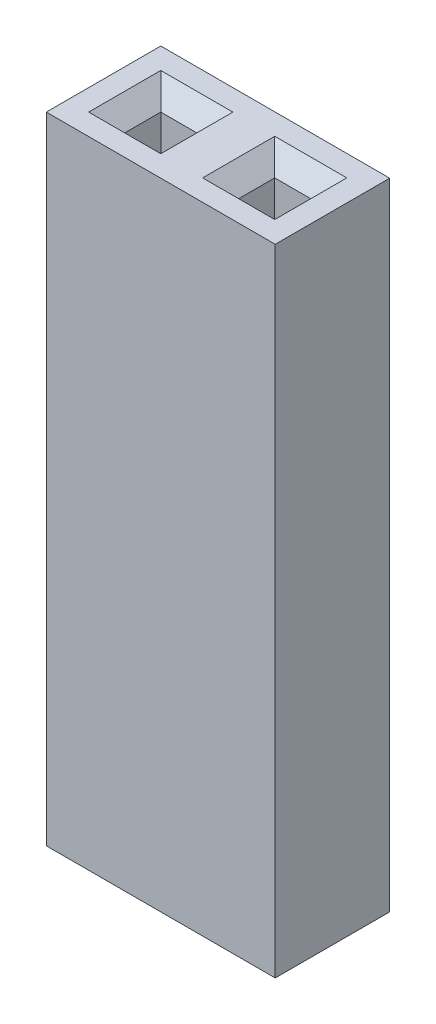
from build123d import *

# Parameters (mm, degrees)
SKETCH_1_W          = 5.08
SKETCH_1_H          = 2.54
EXTRUDE_1_DEPTH     = 14.1
SKETCH_5_W          = 0.8
SKETCH_5_H          = 0.8
CUT_EXTRUDE_5_DEPTH = 10
CHAMFER_5_SIZE      = 0.4
SKETCH_2_W          = 0.8
SKETCH_2_H          = 0.8
CUT_EXTRUDE_2_DEPTH = 10


with BuildPart() as part:
    # Эскиз1 → Бобышка-Вытянуть1 (new body)
    with BuildSketch(Plane(origin=(0, 0, 0), x_dir=(1, 0, 0), z_dir=(0, 1, 0))):
        with Locations((2.54, 1.27)):
            Rectangle(SKETCH_1_W, SKETCH_1_H)
    extrude(amount=EXTRUDE_1_DEPTH)

    # Эскиз5 → Вырез-Вытянуть5 (cut)
    with BuildSketch(Plane(origin=(0, 14.1, 0), x_dir=(1, 0, 0), z_dir=(0, 1, 0))):
        with Locations((1.27, 1.27)):
            Rectangle(SKETCH_5_W, SKETCH_5_H)
        with Locations((3.79891982, 1.27)):
            Rectangle(SKETCH_5_W, SKETCH_5_H)
    extrude(amount=-CUT_EXTRUDE_5_DEPTH, mode=Mode.SUBTRACT)

    # Фаска5
    chamfer_5_edges = [part.edges().sort_by_distance(p)[0] for p in [
        (0.87, 14.1, -1.27),
        (1.27, 14.1, -1.67),
        (1.27, 14.1, -0.87),
        (1.67, 14.1, -1.27),
        (3.39891982, 14.1, -1.27),
        (3.79891982, 14.1, -1.67),
        (3.79891982, 14.1, -0.87),
        (4.19891982, 14.1, -1.27),
    ]]
    chamfer(chamfer_5_edges, length=CHAMFER_5_SIZE)

    # Эскиз2 → Вырез-Вытянуть2 (cut)
    with BuildSketch(Plane(origin=(0, 14.1, 0), x_dir=(1, 0, 0), z_dir=(0, 1, 0))):
        with Locations((1.27, 1.27)):
            Rectangle(SKETCH_2_W, SKETCH_2_H)
        with Locations((3.81, 1.27)):
            Rectangle(SKETCH_2_W, SKETCH_2_H)
    extrude(amount=-CUT_EXTRUDE_2_DEPTH, mode=Mode.SUBTRACT)


solid = part.part
